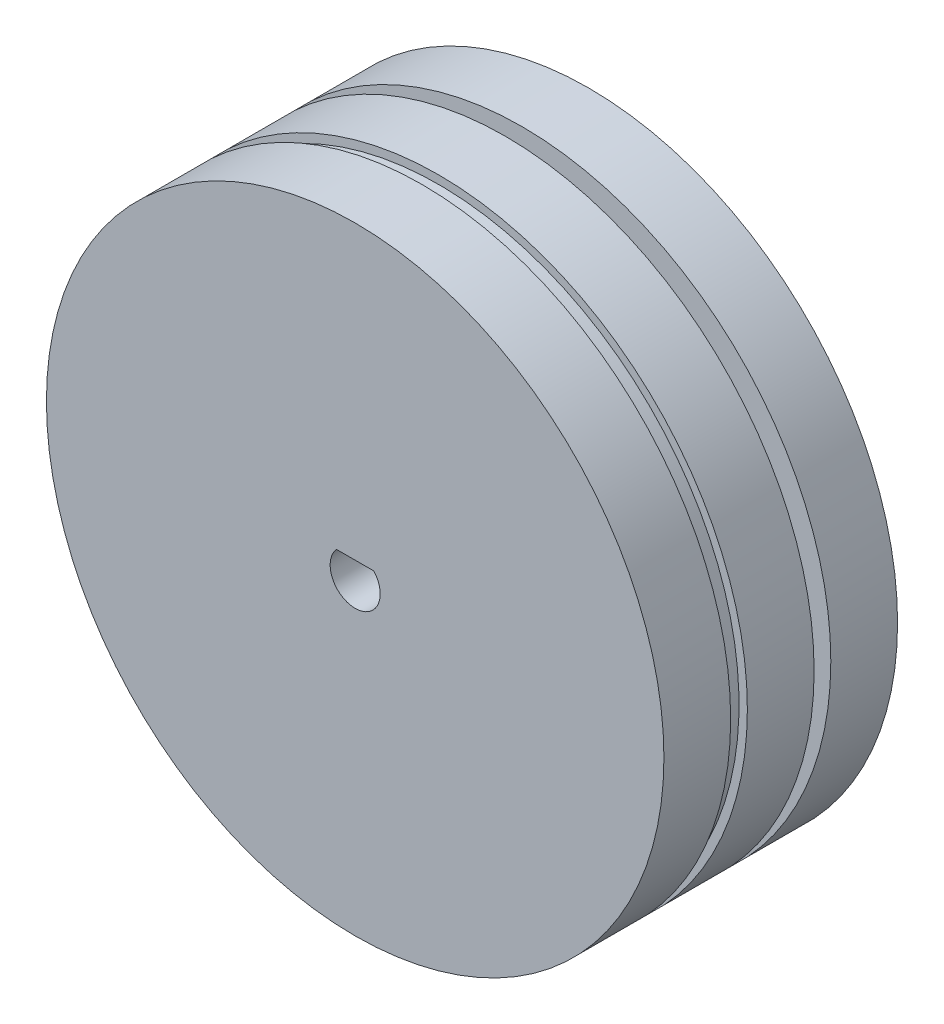
from build123d import *

# Parameters (mm, degrees)
SKETCH_1_R          = 18.5
EXTRUDE_1_DEPTH     = 4
SKETCH_2_R          = 18
EXTRUDE_2_DEPTH     = 1
SKETCH_3_R          = 18.5
EXTRUDE_3_DEPTH     = 4
SKETCH_4_R          = 17
EXTRUDE_4_DEPTH     = 1
SKETCH_5_R          = 18.5
EXTRUDE_5_DEPTH     = 4
CUT_EXTRUDE_1_DEPTH = 6
SKETCH_7_R          = 3
CUT_EXTRUDE_2_DEPTH = 2.5


with BuildPart() as part:
    # 草图1 → 凸台-拉伸1 (new body)
    with BuildSketch(Plane.XY):
        Circle(SKETCH_1_R)
    extrude(amount=EXTRUDE_1_DEPTH)

    # 草图2 → 凸台-拉伸2 (add)
    with BuildSketch(Plane(origin=(0, 0, 0), x_dir=(-1, 0, 0), z_dir=(0, 0, -1))):
        Circle(SKETCH_2_R)
    extrude(amount=EXTRUDE_2_DEPTH)

    # 草图3 → 凸台-拉伸3 (add)
    with BuildSketch(Plane(origin=(0, 0, -1), x_dir=(-1, 0, 0), z_dir=(0, 0, -1))):
        Circle(SKETCH_3_R)
    extrude(amount=EXTRUDE_3_DEPTH)

    # 草图4 → 凸台-拉伸4 (add)
    with BuildSketch(Plane(origin=(0, 0, -5), x_dir=(-1, 0, 0), z_dir=(0, 0, -1))):
        Circle(SKETCH_4_R)
    extrude(amount=EXTRUDE_4_DEPTH)

    # 草图5 → 凸台-拉伸5 (add)
    with BuildSketch(Plane(origin=(0, 0, -6), x_dir=(-1, 0, 0), z_dir=(0, 0, -1))):
        Circle(SKETCH_5_R)
    extrude(amount=EXTRUDE_5_DEPTH)

    # 草图6 → 切除-拉伸1 (cut)
    with BuildSketch(Plane.XY.offset(4)):
        with BuildLine():
            Line((1.118033989, 1), (-1.118033989, 1))
            ThreePointArc((-1.118033989, 1), (0, -1.5), (1.118033989, 1))
        make_face()
    extrude(amount=-CUT_EXTRUDE_1_DEPTH, mode=Mode.SUBTRACT)

    # 草图7 → 切除-拉伸2 (cut)
    with BuildSketch(Plane(origin=(0, 0, -10), x_dir=(-1, 0, 0), z_dir=(0, 0, -1))):
        Circle(SKETCH_7_R)
    extrude(amount=-CUT_EXTRUDE_2_DEPTH, mode=Mode.SUBTRACT)


solid = part.part
